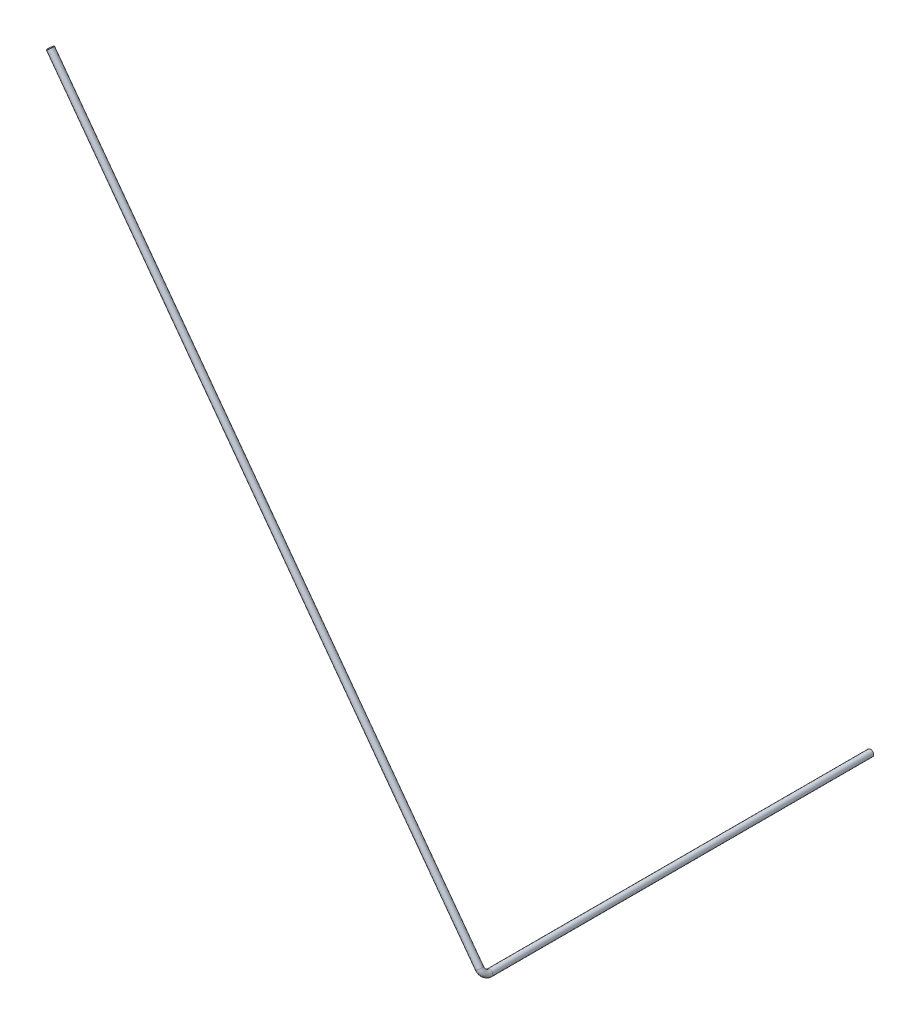
from build123d import *

# Parameters (mm, degrees)
SWEEP_THIN1_PROFILE_R   = 15
SWEEP_THIN1_PROFILE_R_2 = 14


with BuildPart() as part:
    # Sweep-Thin1: sweep along a curve in space
    with BuildLine() as sweep_thin1_path:
        Line((-31046.033515707, -16820.592620356, 41171.211472117), (-31046.033515707, -16820.592620356, 42968.390196057))
        ThreePointArc((-31046.033515707, -16820.592620356, 42968.390196057), (-31051.245107931, -16813.51822283, 42989.603399492), (-31063.827004559, -16796.439116377, 42998.390196057))
        Line((-31063.827004559, -16796.439116377, 42998.390196057), (-33088.750709745, -14047.736870492, 42998.390196057))
    # Sweep-Thin1 profile (on start of the path) → Sweep-Thin1 (sweep)
    with BuildSketch(Plane(origin=(-31046.033515707, -16820.592620356, 41171.211472117), x_dir=(1, 0, 0), z_dir=(0, 0, 1))):
        Circle(SWEEP_THIN1_PROFILE_R)
        Circle(SWEEP_THIN1_PROFILE_R_2, mode=Mode.SUBTRACT)
    sweep(path=sweep_thin1_path.line)


solid = part.part
